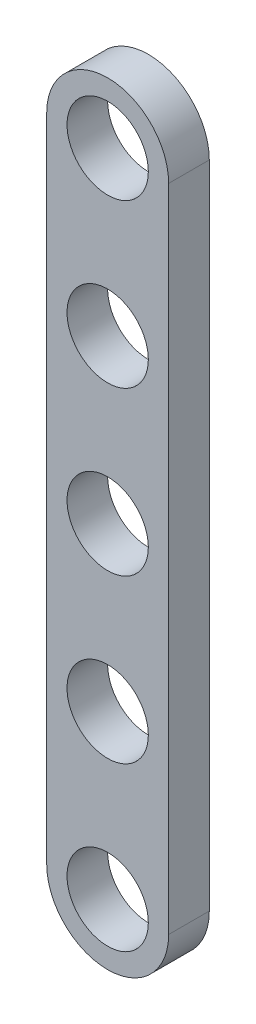
from build123d import *

# Parameters (mm, degrees)
SKETCH_1_R      = 1
EXTRUDE_1_DEPTH = 1


with BuildPart() as part:
    # 草图1 → 凸台-拉伸1 (new body)
    with BuildSketch(Plane.XY):
        with BuildLine():
            Line((-1.5, 0), (-1.5, 16))
            ThreePointArc((-1.5, 16), (0, 17.5), (1.5, 16))
            Line((1.5, 16), (1.5, 0))
            ThreePointArc((1.5, 0), (0, -1.5), (-1.5, 0))
        make_face()
        with Locations((0, 16)):
            Circle(SKETCH_1_R, mode=Mode.SUBTRACT)
        with Locations((0, 8)):
            Circle(SKETCH_1_R, mode=Mode.SUBTRACT)
        with Locations((0, 12)):
            Circle(SKETCH_1_R, mode=Mode.SUBTRACT)
        Circle(SKETCH_1_R, mode=Mode.SUBTRACT)
        with Locations((0, 4)):
            Circle(SKETCH_1_R, mode=Mode.SUBTRACT)
    extrude(amount=EXTRUDE_1_DEPTH)


solid = part.part
